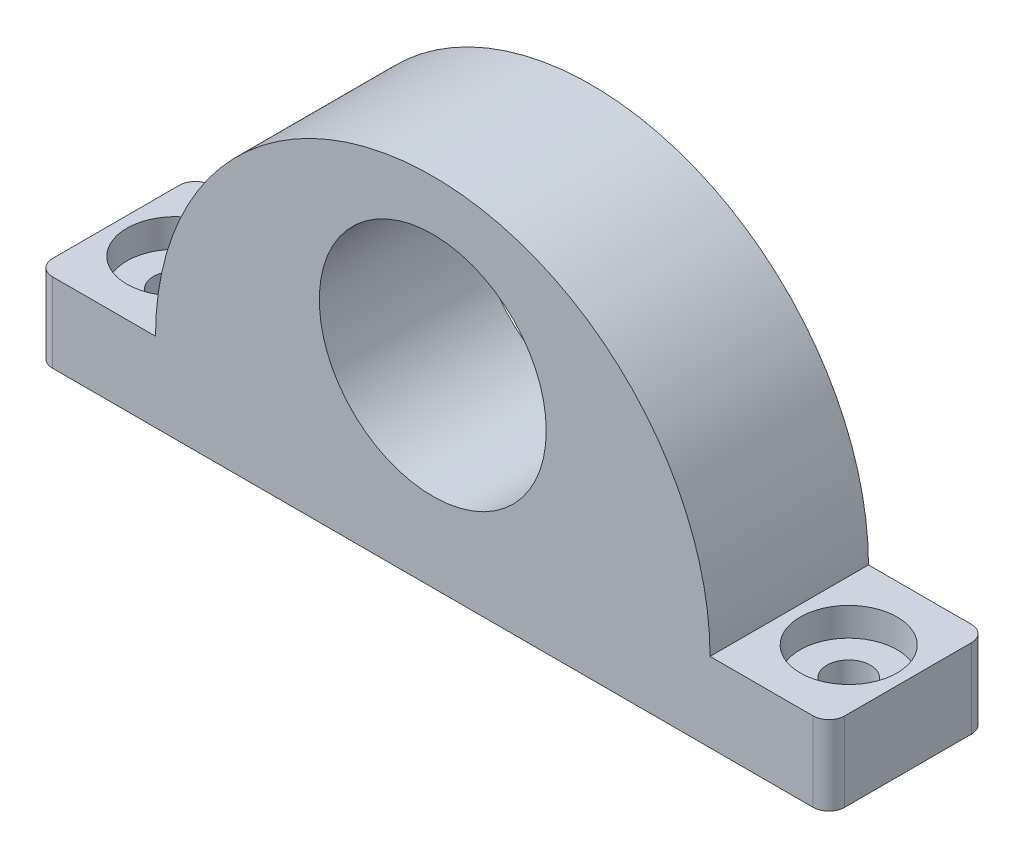
from build123d import *

# Parameters (mm, degrees)
SKETCH3_R                               = 14.325
BOSS_EXTRUDE3_DEPTH                     = 20
CBORE_FOR_M5_HEX_HEAD_BOLT1_D           = 5.5
CBORE_FOR_M5_HEX_HEAD_BOLT1_DEPTH       = 10
CBORE_FOR_M5_HEX_HEAD_BOLT1_CBORE_D     = 12.24
CBORE_FOR_M5_HEX_HEAD_BOLT1_CBORE_DEPTH = 3.58
FILLET1_R                               = 2


with BuildPart() as part:
    # Sketch3 → Boss-Extrude3 (new body)
    with BuildSketch(Plane.XY):
        with BuildLine():
            ThreePointArc((35, 5), (0, 40), (-35, 5))
            Line((-35, 5), (-50, 5))
            Line((-50, 5), (-50, -5))
            Line((-50, -5), (50, -5))
            Line((50, -5), (50, 5))
            Line((50, 5), (35, 5))
        make_face()
        with Locations((0, 19.325)):
            Circle(SKETCH3_R, mode=Mode.SUBTRACT)
    extrude(amount=BOSS_EXTRUDE3_DEPTH)

    # CBORE for M5 Hex Head Bolt1
    with Locations(Plane(origin=(0, 5, 0), x_dir=(1, 0, 0), z_dir=(0, 1, 0))):
        with Locations((-42.5, -10), (42.5, -10)):
            CounterBoreHole(CBORE_FOR_M5_HEX_HEAD_BOLT1_D / 2, CBORE_FOR_M5_HEX_HEAD_BOLT1_CBORE_D / 2, CBORE_FOR_M5_HEX_HEAD_BOLT1_CBORE_DEPTH, depth=CBORE_FOR_M5_HEX_HEAD_BOLT1_DEPTH)

    # Fillet1
    fillet1_edges = [part.edges().sort_by_distance(p)[0] for p in [
        (50, 0, 0),
        (-50, 0, 0),
        (50, 0, 20),
        (-50, 0, 20),
    ]]
    fillet(fillet1_edges, radius=FILLET1_R)


solid = part.part
